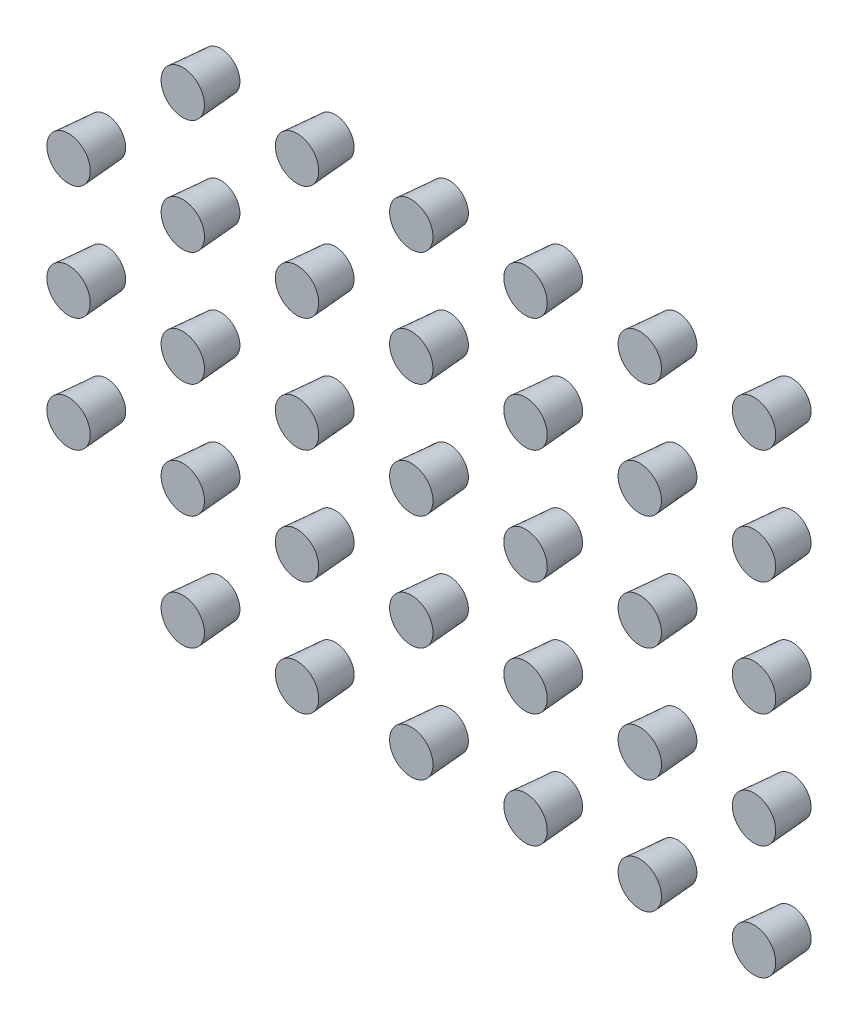
from build123d import *

# Parameters (mm, degrees)
SKETCH_1_R               = 0.5
EXTRUDE_1_DEPTH          = 1
EXTRUDE_1_TAPER          = -4
PATTERN_LINEAR_1_COUNT   = 6
PATTERN_LINEAR_1_PITCH   = 3
PATTERN_LINEAR_1_2_COUNT = 6
PATTERN_LINEAR_1_2_PITCH = 3
PATTERN_LINEAR_2_COUNT   = 2
PATTERN_LINEAR_2_PITCH   = 3
PATTERN_LINEAR_3_COUNT   = 2
PATTERN_LINEAR_3_PITCH   = 3


with BuildPart() as part:
    # 草图1 → 凸台-拉伸1 (new body)
    with BuildSketch(Plane.XY):
        Circle(SKETCH_1_R)
    extrude(amount=EXTRUDE_1_DEPTH, taper=EXTRUDE_1_TAPER)


with BuildPart() as pattern_linear_1_1:
    # 阵列(线性)1: pattern copy
    add(part.part.moved(Location(Vector(0, 1, 0) * (1 * PATTERN_LINEAR_1_PITCH))))


with BuildPart() as pattern_linear_1_2:
    # 阵列(线性)1: pattern copy
    add(part.part.moved(Location(Vector(0, 1, 0) * (2 * PATTERN_LINEAR_1_PITCH))))


with BuildPart() as pattern_linear_1_3:
    # 阵列(线性)1: pattern copy
    add(part.part.moved(Location(Vector(0, 1, 0) * (3 * PATTERN_LINEAR_1_PITCH))))


with BuildPart() as pattern_linear_1_4:
    # 阵列(线性)1: pattern copy
    add(part.part.moved(Location(Vector(0, 1, 0) * (4 * PATTERN_LINEAR_1_PITCH))))


with BuildPart() as pattern_linear_1_5:
    # 阵列(线性)1: pattern copy
    add(part.part.moved(Location(Vector(0, 1, 0) * (5 * PATTERN_LINEAR_1_PITCH))))


with BuildPart() as pattern_linear_1_2_1:
    # Pattern Linear 1 2: pattern copy
    add(part.part.moved(Location(Vector(1, 0, 0) * (1 * PATTERN_LINEAR_1_2_PITCH))))


with BuildPart() as pattern_linear_1_2_2:
    # Pattern Linear 1 2: pattern copy
    add(part.part.moved(Location(Vector(1, 0, 0) * (2 * PATTERN_LINEAR_1_2_PITCH))))


with BuildPart() as pattern_linear_1_2_3:
    # Pattern Linear 1 2: pattern copy
    add(part.part.moved(Location(Vector(1, 0, 0) * (3 * PATTERN_LINEAR_1_2_PITCH))))


with BuildPart() as pattern_linear_1_2_4:
    # Pattern Linear 1 2: pattern copy
    add(part.part.moved(Location(Vector(1, 0, 0) * (4 * PATTERN_LINEAR_1_2_PITCH))))


with BuildPart() as pattern_linear_1_2_5:
    # Pattern Linear 1 2: pattern copy
    add(part.part.moved(Location(Vector(1, 0, 0) * (5 * PATTERN_LINEAR_1_2_PITCH))))


with BuildPart() as pattern_linear_1_2_6:
    # Pattern Linear 1 2: pattern copy
    add(pattern_linear_1_1.part.moved(Location(Vector(1, 0, 0) * (1 * PATTERN_LINEAR_1_2_PITCH))))


with BuildPart() as pattern_linear_1_2_7:
    # Pattern Linear 1 2: pattern copy
    add(pattern_linear_1_1.part.moved(Location(Vector(1, 0, 0) * (2 * PATTERN_LINEAR_1_2_PITCH))))


with BuildPart() as pattern_linear_1_2_8:
    # Pattern Linear 1 2: pattern copy
    add(pattern_linear_1_1.part.moved(Location(Vector(1, 0, 0) * (3 * PATTERN_LINEAR_1_2_PITCH))))


with BuildPart() as pattern_linear_1_2_9:
    # Pattern Linear 1 2: pattern copy
    add(pattern_linear_1_1.part.moved(Location(Vector(1, 0, 0) * (4 * PATTERN_LINEAR_1_2_PITCH))))


with BuildPart() as pattern_linear_1_2_10:
    # Pattern Linear 1 2: pattern copy
    add(pattern_linear_1_1.part.moved(Location(Vector(1, 0, 0) * (5 * PATTERN_LINEAR_1_2_PITCH))))


with BuildPart() as pattern_linear_1_2_11:
    # Pattern Linear 1 2: pattern copy
    add(pattern_linear_1_2.part.moved(Location(Vector(1, 0, 0) * (1 * PATTERN_LINEAR_1_2_PITCH))))


with BuildPart() as pattern_linear_1_2_12:
    # Pattern Linear 1 2: pattern copy
    add(pattern_linear_1_2.part.moved(Location(Vector(1, 0, 0) * (2 * PATTERN_LINEAR_1_2_PITCH))))


with BuildPart() as pattern_linear_1_2_13:
    # Pattern Linear 1 2: pattern copy
    add(pattern_linear_1_2.part.moved(Location(Vector(1, 0, 0) * (3 * PATTERN_LINEAR_1_2_PITCH))))


with BuildPart() as pattern_linear_1_2_14:
    # Pattern Linear 1 2: pattern copy
    add(pattern_linear_1_2.part.moved(Location(Vector(1, 0, 0) * (4 * PATTERN_LINEAR_1_2_PITCH))))


with BuildPart() as pattern_linear_1_2_15:
    # Pattern Linear 1 2: pattern copy
    add(pattern_linear_1_2.part.moved(Location(Vector(1, 0, 0) * (5 * PATTERN_LINEAR_1_2_PITCH))))


with BuildPart() as pattern_linear_1_2_16:
    # Pattern Linear 1 2: pattern copy
    add(pattern_linear_1_3.part.moved(Location(Vector(1, 0, 0) * (1 * PATTERN_LINEAR_1_2_PITCH))))


with BuildPart() as pattern_linear_1_2_17:
    # Pattern Linear 1 2: pattern copy
    add(pattern_linear_1_3.part.moved(Location(Vector(1, 0, 0) * (2 * PATTERN_LINEAR_1_2_PITCH))))


with BuildPart() as pattern_linear_1_2_18:
    # Pattern Linear 1 2: pattern copy
    add(pattern_linear_1_3.part.moved(Location(Vector(1, 0, 0) * (3 * PATTERN_LINEAR_1_2_PITCH))))


with BuildPart() as pattern_linear_1_2_19:
    # Pattern Linear 1 2: pattern copy
    add(pattern_linear_1_3.part.moved(Location(Vector(1, 0, 0) * (4 * PATTERN_LINEAR_1_2_PITCH))))


with BuildPart() as pattern_linear_1_2_20:
    # Pattern Linear 1 2: pattern copy
    add(pattern_linear_1_3.part.moved(Location(Vector(1, 0, 0) * (5 * PATTERN_LINEAR_1_2_PITCH))))


with BuildPart() as pattern_linear_1_2_21:
    # Pattern Linear 1 2: pattern copy
    add(pattern_linear_1_4.part.moved(Location(Vector(1, 0, 0) * (1 * PATTERN_LINEAR_1_2_PITCH))))


with BuildPart() as pattern_linear_1_2_22:
    # Pattern Linear 1 2: pattern copy
    add(pattern_linear_1_4.part.moved(Location(Vector(1, 0, 0) * (2 * PATTERN_LINEAR_1_2_PITCH))))


with BuildPart() as pattern_linear_1_2_23:
    # Pattern Linear 1 2: pattern copy
    add(pattern_linear_1_4.part.moved(Location(Vector(1, 0, 0) * (3 * PATTERN_LINEAR_1_2_PITCH))))


with BuildPart() as pattern_linear_1_2_24:
    # Pattern Linear 1 2: pattern copy
    add(pattern_linear_1_4.part.moved(Location(Vector(1, 0, 0) * (4 * PATTERN_LINEAR_1_2_PITCH))))


with BuildPart() as pattern_linear_1_2_25:
    # Pattern Linear 1 2: pattern copy
    add(pattern_linear_1_4.part.moved(Location(Vector(1, 0, 0) * (5 * PATTERN_LINEAR_1_2_PITCH))))


with BuildPart() as pattern_linear_1_2_26:
    # Pattern Linear 1 2: pattern copy
    add(pattern_linear_1_5.part.moved(Location(Vector(1, 0, 0) * (1 * PATTERN_LINEAR_1_2_PITCH))))


with BuildPart() as pattern_linear_1_2_27:
    # Pattern Linear 1 2: pattern copy
    add(pattern_linear_1_5.part.moved(Location(Vector(1, 0, 0) * (2 * PATTERN_LINEAR_1_2_PITCH))))


with BuildPart() as pattern_linear_1_2_28:
    # Pattern Linear 1 2: pattern copy
    add(pattern_linear_1_5.part.moved(Location(Vector(1, 0, 0) * (3 * PATTERN_LINEAR_1_2_PITCH))))


with BuildPart() as pattern_linear_1_2_29:
    # Pattern Linear 1 2: pattern copy
    add(pattern_linear_1_5.part.moved(Location(Vector(1, 0, 0) * (4 * PATTERN_LINEAR_1_2_PITCH))))


with BuildPart() as pattern_linear_1_2_30:
    # Pattern Linear 1 2: pattern copy
    add(pattern_linear_1_5.part.moved(Location(Vector(1, 0, 0) * (5 * PATTERN_LINEAR_1_2_PITCH))))


with BuildPart() as pattern_linear_2_1:
    # 阵列(线性)2: pattern copy
    add(pattern_linear_1_4.part.moved(Location(Vector(-1, 0, 0) * (1 * PATTERN_LINEAR_2_PITCH))))


with BuildPart() as pattern_linear_2_2:
    # 阵列(线性)2: pattern copy
    add(pattern_linear_1_3.part.moved(Location(Vector(-1, 0, 0) * (1 * PATTERN_LINEAR_2_PITCH))))


with BuildPart() as pattern_linear_2_3:
    # 阵列(线性)2: pattern copy
    add(pattern_linear_1_2.part.moved(Location(Vector(-1, 0, 0) * (1 * PATTERN_LINEAR_2_PITCH))))


with BuildPart() as pattern_linear_2_4:
    # 阵列(线性)2: pattern copy
    add(pattern_linear_1_1.part.moved(Location(Vector(-1, 0, 0) * (1 * PATTERN_LINEAR_2_PITCH))))


with BuildPart() as pattern_linear_3_1:
    # 阵列(线性)3: pattern copy
    add(pattern_linear_2_2.part.moved(Location(Vector(-1, 0, 0) * (1 * PATTERN_LINEAR_3_PITCH))))


with BuildPart() as pattern_linear_3_2:
    # 阵列(线性)3: pattern copy
    add(pattern_linear_2_3.part.moved(Location(Vector(-1, 0, 0) * (1 * PATTERN_LINEAR_3_PITCH))))


solid = Compound([pattern_linear_1_1.part, pattern_linear_1_2.part, pattern_linear_1_3.part, pattern_linear_1_4.part, pattern_linear_1_5.part, pattern_linear_1_2_6.part, pattern_linear_1_2_7.part, pattern_linear_1_2_8.part, pattern_linear_1_2_9.part, pattern_linear_1_2_10.part, pattern_linear_1_2_11.part, pattern_linear_1_2_12.part, pattern_linear_1_2_13.part, pattern_linear_1_2_14.part, pattern_linear_1_2_15.part, pattern_linear_1_2_16.part, pattern_linear_1_2_17.part, pattern_linear_1_2_18.part, pattern_linear_1_2_19.part, pattern_linear_1_2_20.part, pattern_linear_1_2_21.part, pattern_linear_1_2_22.part, pattern_linear_1_2_23.part, pattern_linear_1_2_24.part, pattern_linear_1_2_25.part, pattern_linear_1_2_26.part, pattern_linear_1_2_27.part, pattern_linear_1_2_28.part, pattern_linear_1_2_29.part, pattern_linear_1_2_30.part, pattern_linear_2_1.part, pattern_linear_2_2.part, pattern_linear_2_3.part])
